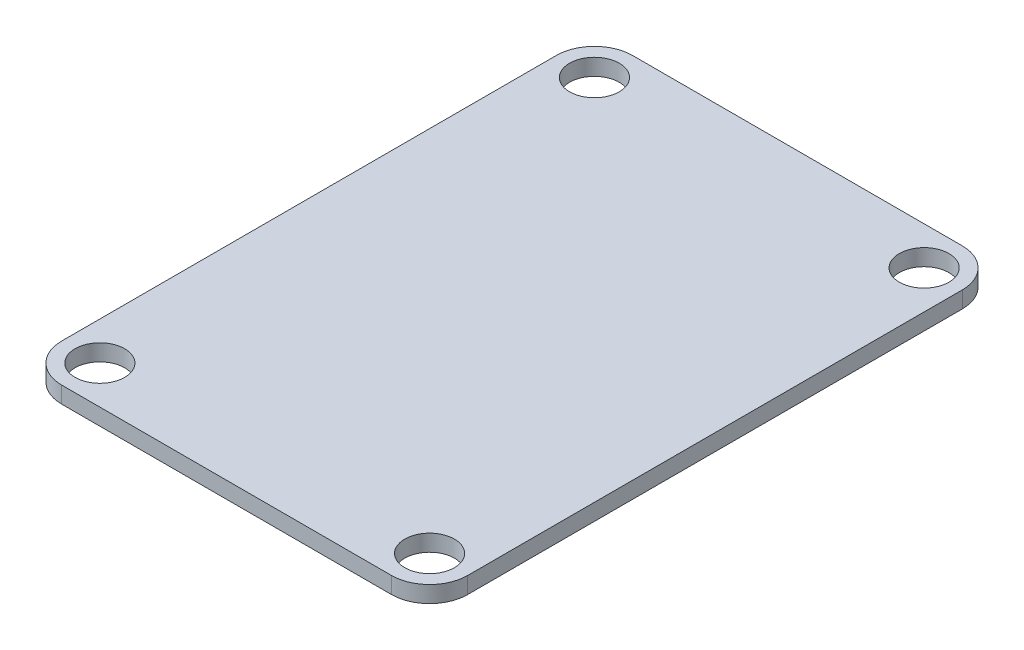
from build123d import *

# Parameters (mm, degrees)
SKETCH1_R           = 2.4
BOSS_EXTRUDE1_DEPTH = 1.6


with BuildPart() as part:
    # Sketch1 → Boss-Extrude1 (new body)
    with BuildSketch(Plane(origin=(0, 0, 0), x_dir=(1, 0, 0), z_dir=(0, 1, 0))):
        with BuildLine():
            Line((-15.94, 27.6), (15.94, 27.6))
            ThreePointArc((15.94, 27.6), (18.549224023, 26.519224023), (19.63, 23.91))
            Line((19.63, 23.91), (19.63, -23.91))
            ThreePointArc((19.63, -23.91), (18.549224023, -26.519224023), (15.94, -27.6))
            Line((15.94, -27.6), (-15.94, -27.6))
            ThreePointArc((-15.94, -27.6), (-18.549224023, -26.519224023), (-19.63, -23.91))
            Line((-19.63, -23.91), (-19.63, 23.91))
            ThreePointArc((-19.63, 23.91), (-18.549224023, 26.519224023), (-15.94, 27.6))
        make_face()
        with Locations((-15.94, 23.91)):
            Circle(SKETCH1_R, mode=Mode.SUBTRACT)
        with Locations((15.94, 23.91)):
            Circle(SKETCH1_R, mode=Mode.SUBTRACT)
        with Locations((15.94, -23.91)):
            Circle(SKETCH1_R, mode=Mode.SUBTRACT)
        with Locations((-15.94, -23.91)):
            Circle(SKETCH1_R, mode=Mode.SUBTRACT)
    extrude(amount=BOSS_EXTRUDE1_DEPTH)


solid = part.part
